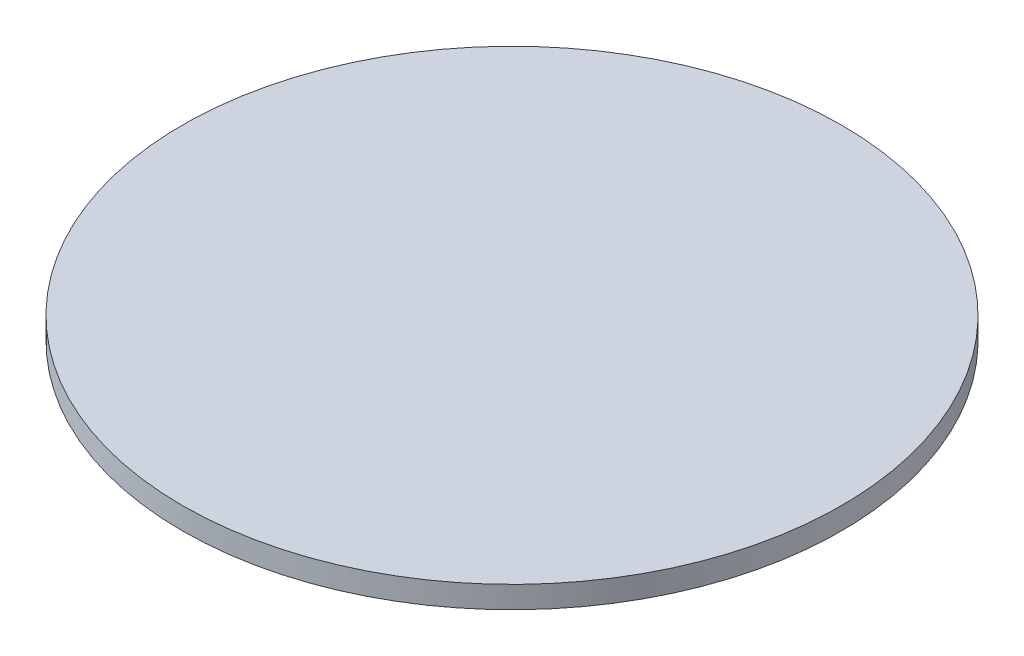
from build123d import *

# Parameters (mm, degrees)
SKETCH1_R           = 1.5
BOSS_EXTRUDE1_DEPTH = 0.1


with BuildPart() as part:
    # Sketch1 → Boss-Extrude1 (new body)
    with BuildSketch(Plane(origin=(0, 0, 0), x_dir=(1, 0, 0), z_dir=(0, 1, 0))):
        Circle(SKETCH1_R)
    extrude(amount=BOSS_EXTRUDE1_DEPTH)


solid = part.part
